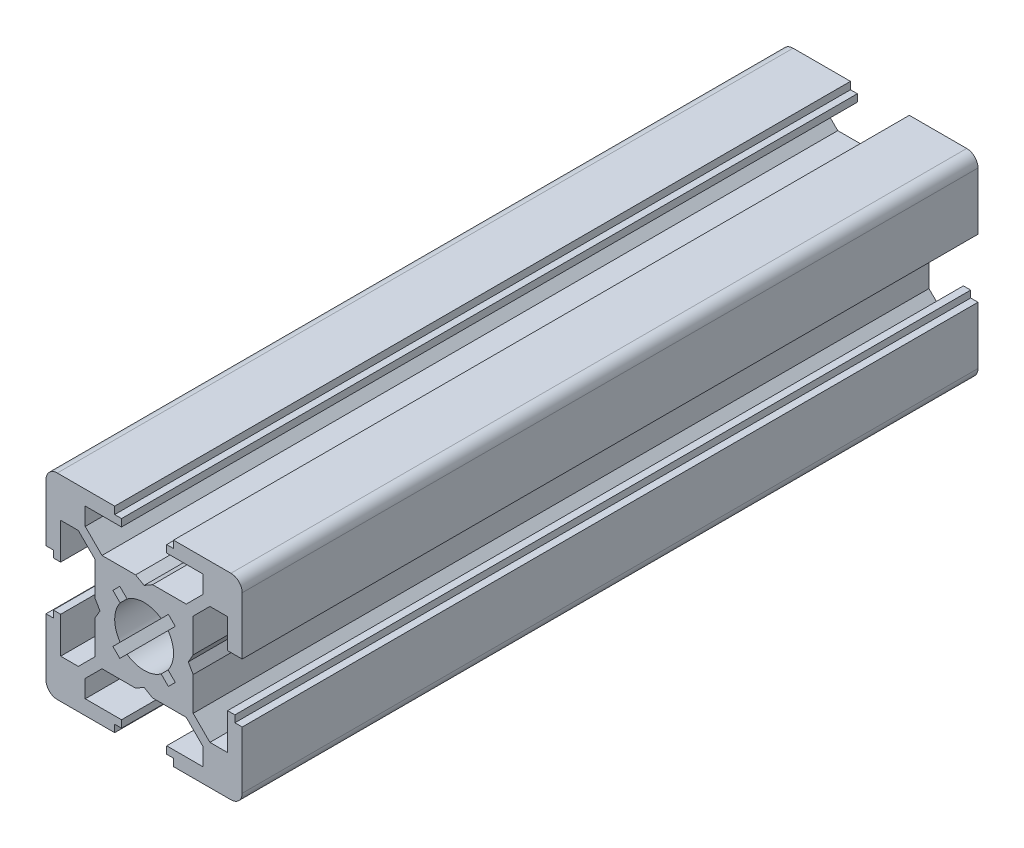
from build123d import *

# Parameters (mm, degrees)
RESSALTO_EXTRUS_O1_DEPTH = 37.5


with BuildPart() as part:
    # Esboço1 → Ressalto-extrusão1 (new body, symmetric)
    with BuildSketch(Plane.XY):
        with BuildLine():
            Line((-6, -8.507783687), (-6, -6.707106781))
            Line((-6, -6.707106781), (-4.292893219, -5))
            Line((-4.292893219, -5), (-0.866025404, -5))
            Line((-0.866025404, -5), (0, -4.5))
            Line((0, -4.5), (0.866025404, -5))
            Line((0.866025404, -5), (4.292893219, -5))
            Line((4.292893219, -5), (6, -6.707106781))
            Line((6, -6.707106781), (6, -8.507783687))
            Line((6, -8.507783687), (2.3, -8.507783687))
            Line((2.3, -8.507783687), (2.3, -9.253891844))
            Line((2.3, -9.253891844), (3, -9.253891844))
            Line((3, -9.253891844), (3, -10))
            Line((3, -10), (8.85, -10))
            ThreePointArc((8.85, -10), (9.663172798, -9.663172798), (10, -8.85))
            Line((10, -8.85), (10, -3))
            Line((10, -3), (9.253891844, -3))
            Line((9.253891844, -3), (9.253891844, -2.3))
            Line((9.253891844, -2.3), (8.507783687, -2.3))
            Line((8.507783687, -2.3), (8.507783687, -6))
            Line((8.507783687, -6), (6.707106781, -6))
            Line((6.707106781, -6), (5, -4.292893219))
            Line((5, -4.292893219), (5, -0.867675042))
            Line((5, -0.867675042), (4.502666183, 0))
            Line((4.502666183, 0), (5, 0.866025404))
            Line((5, 0.866025404), (5, 4.292893219))
            Line((5, 4.292893219), (6.707106781, 6))
            Line((6.707106781, 6), (8.507783687, 6))
            Line((8.507783687, 6), (8.507783687, 3))
            Line((8.507783687, 3), (9.253891844, 3))
            Line((9.253891844, 3), (10, 3))
            Line((10, 3), (10, 8.85))
            ThreePointArc((10, 8.85), (9.663172798, 9.663172798), (8.85, 10))
            Line((8.85, 10), (3, 10))
            Line((3, 10), (3, 9.253891844))
            Line((3, 9.253891844), (2.3, 9.253891844))
            Line((2.3, 9.253891844), (2.3, 8.507783687))
            Line((2.3, 8.507783687), (6, 8.507783687))
            Line((6, 8.507783687), (6, 6.707106781))
            Line((6, 6.707106781), (4.292893219, 5))
            Line((4.292893219, 5), (0.866025404, 5))
            Line((0.866025404, 5), (0, 4.502147794))
            Line((0, 4.502147794), (-0.866025404, 5))
            Line((-0.866025404, 5), (-4.292893219, 5))
            Line((-4.292893219, 5), (-6, 6.707106781))
            Line((-6, 6.707106781), (-6, 8.507783687))
            Line((-6, 8.507783687), (-2.3, 8.507783687))
            Line((-2.3, 8.507783687), (-2.3, 9.253891844))
            Line((-2.3, 9.253891844), (-3, 9.253891844))
            Line((-3, 9.253891844), (-3, 10))
            Line((-3, 10), (-8.85, 10))
            ThreePointArc((-8.85, 10), (-9.663172798, 9.663172798), (-10, 8.85))
            Line((-10, 8.85), (-10, 3))
            Line((-10, 3), (-9.253891844, 3))
            Line((-9.253891844, 3), (-9.253891844, 2.3))
            Line((-9.253891844, 2.3), (-8.507783687, 2.3))
            Line((-8.507783687, 2.3), (-8.507783687, 6))
            Line((-8.507783687, 6), (-6.707106781, 6))
            Line((-6.707106781, 6), (-5, 4.292893219))
            Line((-5, 4.292893219), (-5, 0.866025404))
            Line((-5, 0.866025404), (-4.498098017, -0.000824819))
            Line((-4.498098017, -0.000824819), (-5, -0.867675042))
            Line((-5, -0.867675042), (-5, -4.292893219))
            Line((-5, -4.292893219), (-6.707106781, -6))
            Line((-6.707106781, -6), (-8.507783687, -6))
            Line((-8.507783687, -6), (-8.507783687, -2.3))
            Line((-8.507783687, -2.3), (-9.253891844, -2.3))
            Line((-9.253891844, -2.3), (-9.253891844, -3))
            Line((-9.253891844, -3), (-10, -3))
            Line((-10, -3), (-10, -8.85))
            ThreePointArc((-10, -8.85), (-9.663172798, -9.663172798), (-8.85, -10))
            Line((-8.85, -10), (-3, -10))
            Line((-3, -10), (-3, -9.253891844))
            Line((-3, -9.253891844), (-2.3, -9.253891844))
            Line((-2.3, -9.253891844), (-2.3, -8.507783687))
            Line((-2.3, -8.507783687), (-6, -8.507783687))
        make_face()
        with BuildLine():
            Line((-2.445203457, 1.738096676), (-3.181980515, 2.474873734))
            Line((-3.181980515, 2.474873734), (-2.474873734, 3.181980515))
            Line((-2.474873734, 3.181980515), (-1.738096676, 2.445203457))
            ThreePointArc((-1.738096676, 2.445203457), (0, 3), (1.738096676, 2.445203457))
            Line((1.738096676, 2.445203457), (2.474873734, 3.181980515))
            Line((2.474873734, 3.181980515), (3.181980515, 2.474873734))
            Line((3.181980515, 2.474873734), (2.445203457, 1.738096676))
            ThreePointArc((2.445203457, 1.738096676), (3, 0), (2.445203457, -1.738096676))
            Line((2.445203457, -1.738096676), (3.181980515, -2.474873734))
            Line((3.181980515, -2.474873734), (2.474873734, -3.181980515))
            Line((2.474873734, -3.181980515), (1.738096676, -2.445203457))
            ThreePointArc((1.738096676, -2.445203457), (0, -3), (-1.738096676, -2.445203457))
            Line((-1.738096676, -2.445203457), (-2.474873734, -3.181980515))
            Line((-2.474873734, -3.181980515), (-3.181980515, -2.474873734))
            Line((-3.181980515, -2.474873734), (-2.445203457, -1.738096676))
            ThreePointArc((-2.445203457, -1.738096676), (-3, 0), (-2.445203457, 1.738096676))
        make_face(mode=Mode.SUBTRACT)
    extrude(amount=RESSALTO_EXTRUS_O1_DEPTH, both=True)


solid = part.part
